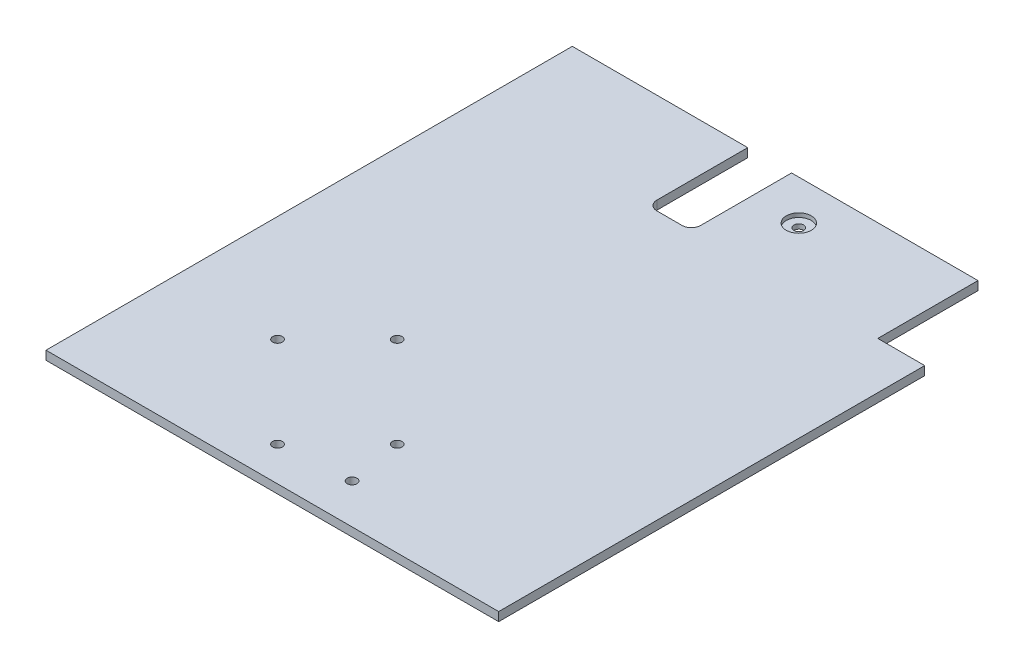
from build123d import *

# Parameters (mm, degrees)
SKETCH1_W           = 144.5
SKETCH1_H           = 168
BOSS_EXTRUDE1_DEPTH = 2.8
CUT_EXTRUDE1_REACH  = 4.8
SKETCH2_R           = 1.55
SKETCH2_W           = 15
SKETCH2_H           = 32
CUT_EXTRUDE2_REACH  = 4.8
SKETCH5_R           = 1.55
SKETCH6_R           = 4
CUT_EXTRUDE3_DEPTH  = 1.3
CUT_EXTRUDE4_REACH  = 4.8


with BuildPart() as part:
    # Sketch1 → Boss-Extrude1 (new body)
    with BuildSketch(Plane(origin=(0, 0, 0), x_dir=(1, 0, 0), z_dir=(0, 1, 0))):
        Rectangle(SKETCH1_W, SKETCH1_H)
    extrude(amount=BOSS_EXTRUDE1_DEPTH)

    # Sketch2 → Cut-Extrude1 (cut, up to next)
    with BuildSketch(Plane(origin=(0, 2.8, 0), x_dir=(1, 0, 0), z_dir=(0, 1, 0)), mode=Mode.PRIVATE) as cut_extrude1_sk1:
        with Locations((-19.199747468, -24.95836944)):
            Circle(SKETCH2_R)
    cut_extrude1_tool1 = extrude(cut_extrude1_sk1.sketch, amount=-CUT_EXTRUDE1_REACH, mode=Mode.PRIVATE) & part.part
    add(cut_extrude1_tool1.solids().sort_by_distance((-19.199747, 2.8, 24.958369))[0], mode=Mode.SUBTRACT)
    # Sketch2 → Cut-Extrude1 (cut, up to next)
    with BuildSketch(Plane(origin=(0, 2.8, 0), x_dir=(1, 0, 0), z_dir=(0, 1, 0)), mode=Mode.PRIVATE) as cut_extrude1_sk2:
        with Locations((9.79163056, -53.949747468)):
            Circle(SKETCH2_R)
    cut_extrude1_tool2 = extrude(cut_extrude1_sk2.sketch, amount=-CUT_EXTRUDE1_REACH, mode=Mode.PRIVATE) & part.part
    add(cut_extrude1_tool2.solids().sort_by_distance((9.791631, 2.8, 53.949747))[0], mode=Mode.SUBTRACT)
    # Sketch2 → Cut-Extrude1 (cut, up to next)
    with BuildSketch(Plane(origin=(0, 2.8, 0), x_dir=(1, 0, 0), z_dir=(0, 1, 0)), mode=Mode.PRIVATE) as cut_extrude1_sk3:
        with Locations((-9.300252532, -73.04163056)):
            Circle(SKETCH2_R)
    cut_extrude1_tool3 = extrude(cut_extrude1_sk3.sketch, amount=-CUT_EXTRUDE1_REACH, mode=Mode.PRIVATE) & part.part
    add(cut_extrude1_tool3.solids().sort_by_distance((-9.300253, 2.8, 73.041631))[0], mode=Mode.SUBTRACT)
    # Sketch2 → Cut-Extrude1 (cut, up to next)
    with BuildSketch(Plane(origin=(0, 2.8, 0), x_dir=(1, 0, 0), z_dir=(0, 1, 0)), mode=Mode.PRIVATE) as cut_extrude1_sk4:
        with Locations((-38.29163056, -44.050252532)):
            Circle(SKETCH2_R)
    cut_extrude1_tool4 = extrude(cut_extrude1_sk4.sketch, amount=-CUT_EXTRUDE1_REACH, mode=Mode.PRIVATE) & part.part
    add(cut_extrude1_tool4.solids().sort_by_distance((-38.291631, 2.8, 44.050253))[0], mode=Mode.SUBTRACT)
    # Sketch2 → Cut-Extrude1 (cut, up to next)
    with BuildSketch(Plane(origin=(0, 2.8, 0), x_dir=(1, 0, 0), z_dir=(0, 1, 0)), mode=Mode.PRIVATE) as cut_extrude1_sk5:
        with Locations((64.75, 68)):
            Rectangle(SKETCH2_W, SKETCH2_H)
    cut_extrude1_tool5 = extrude(cut_extrude1_sk5.sketch, amount=-CUT_EXTRUDE1_REACH, mode=Mode.PRIVATE) & part.part
    add(cut_extrude1_tool5.solids().sort_by_distance((64.75, 2.8, -68))[0], mode=Mode.SUBTRACT)

    # Sketch5 → Cut-Extrude2 (cut, up to next)
    with BuildSketch(Plane(origin=(0, 2.8, 0), x_dir=(1, 0, 0), z_dir=(0, 1, 0)), mode=Mode.PRIVATE) as cut_extrude2_sk1:
        with Locations((12.75, 71.3)):
            Circle(SKETCH5_R)
    cut_extrude2_tool1 = extrude(cut_extrude2_sk1.sketch, amount=-CUT_EXTRUDE2_REACH, mode=Mode.PRIVATE) & part.part
    add(cut_extrude2_tool1.solids().sort_by_distance((12.75, 2.8, -71.3))[0], mode=Mode.SUBTRACT)
    # Sketch5 → Cut-Extrude2 (cut, up to next)
    with BuildSketch(Plane(origin=(0, 2.8, 0), x_dir=(1, 0, 0), z_dir=(0, 1, 0)), mode=Mode.PRIVATE) as cut_extrude2_sk2:
        with Locations((12.75, -71.3)):
            Circle(SKETCH5_R)
    cut_extrude2_tool2 = extrude(cut_extrude2_sk2.sketch, amount=-CUT_EXTRUDE2_REACH, mode=Mode.PRIVATE) & part.part
    add(cut_extrude2_tool2.solids().sort_by_distance((12.75, 2.8, 71.3))[0], mode=Mode.SUBTRACT)

    # Sketch6 → Cut-Extrude3 (cut)
    with BuildSketch(Plane(origin=(0, 2.8, 0), x_dir=(1, 0, 0), z_dir=(0, 1, 0))):
        with Locations((12.75, 71.3)):
            Circle(SKETCH6_R)
    extrude(amount=-CUT_EXTRUDE3_DEPTH, mode=Mode.SUBTRACT)

    # Sketch7 → Cut-Extrude4 (cut, up to next)
    with BuildSketch(Plane(origin=(0, 2.8, 0), x_dir=(1, 0, 0), z_dir=(0, 1, 0)), mode=Mode.PRIVATE) as cut_extrude4_sk1:
        with BuildLine():
            Line((-16.25, 84), (-16.25, 55))
            ThreePointArc((-16.25, 55), (-15.371320344, 52.878679656), (-13.25, 52))
            Line((-13.25, 52), (-5.25, 52))
            ThreePointArc((-5.25, 52), (-3.128679656, 52.878679656), (-2.25, 55))
            Line((-2.25, 55), (-2.25, 84))
            Line((-2.25, 84), (-16.25, 84))
        make_face()
    cut_extrude4_tool1 = extrude(cut_extrude4_sk1.sketch, amount=-CUT_EXTRUDE4_REACH, mode=Mode.PRIVATE) & part.part
    add(cut_extrude4_tool1.solids().sort_by_distance((-9.25, 2.8, -68.13333))[0], mode=Mode.SUBTRACT)


solid = part.part
